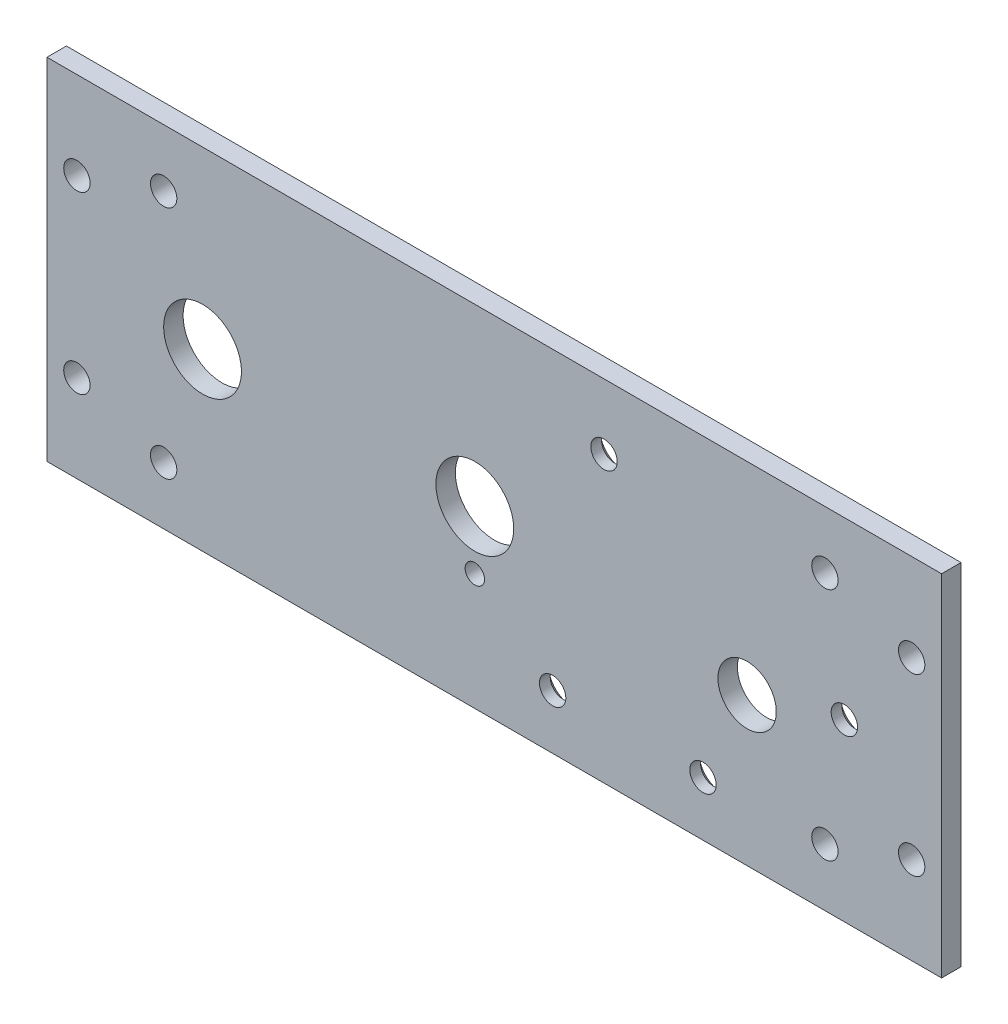
from build123d import *

# Parameters (mm, degrees)
SKETCH1_W                                 = 146.05
SKETCH1_H                                 = 57.15
BOSS_EXTRUDE1_DEPTH                       = 3.175
F_6_CLEARANCE_HOLE1_D                     = 4.3053
F_1_2_0_5_DIAMETER_HOLE1_D                = 12.7
F_3_8_0_375_DIAMETER_HOLE1_D              = 9.525
F_1_8_0_125_DIAMETER_HOLE1_D              = 3.175
CSK_FOR_6_FLAT_HEAD_MACHINE_SCREW_2_COUNT = 2
CSK_FOR_6_FLAT_HEAD_MACHINE_SCREW_2_PITCH = 38.528341037
CSK_FOR_6_FLAT_HEAD_MACHINE_SCREW_3_COUNT = 2
CSK_FOR_6_FLAT_HEAD_MACHINE_SCREW_3_PITCH = 51.534810808
CSK_FOR_6_FLAT_HEAD_MACHINE_SCREW_4_COUNT = 2
CSK_FOR_6_FLAT_HEAD_MACHINE_SCREW_4_PITCH = 24.55


with BuildPart() as part:
    # Sketch1 → Boss-Extrude1 (new body)
    with BuildSketch(Plane.XY):
        with Locations((-73.025, 28.575)):
            Rectangle(SKETCH1_W, SKETCH1_H)
    extrude(amount=-BOSS_EXTRUDE1_DEPTH)

    # #6 Clearance Hole1 (through all)
    with Locations(Plane(origin=(0, 0, -3.175), x_dir=(-1, 0, 0), z_dir=(0, 0, -1))):
        with Locations((4.8895, 42.8625), (141.1605, 42.8625), (141.1605, 14.2875), (4.8895, 14.2875), (19.05, 47.752), (19.05, 9.398), (127, 9.398), (127, 47.752)):
            Hole(F_6_CLEARANCE_HOLE1_D / 2)

    # 1/2 (0.5) Diameter Hole1 (through all)
    with Locations(Plane(origin=(0, 0, -3.175), x_dir=(-1, 0, 0), z_dir=(0, 0, -1))):
        with Locations((76.2, 28.575), (120.65, 28.575)):
            Hole(F_1_2_0_5_DIAMETER_HOLE1_D / 2)

    # 3/8 (0.375) Diameter Hole1 (through all)
    with Locations(Plane(origin=(0, 0, -3.175), x_dir=(-1, 0, 0), z_dir=(0, 0, -1))):
        with Locations((31.75, 24.13)):
            Hole(F_3_8_0_375_DIAMETER_HOLE1_D / 2)

    # 1/8 (0.125) Diameter Hole1 (through all)
    with Locations(Plane(origin=(0, 0, -3.175), x_dir=(-1, 0, 0), z_dir=(0, 0, -1))):
        with Locations((76.2, 19.05)):
            Hole(F_1_8_0_125_DIAMETER_HOLE1_D / 2)

    # Sketch14 → CSK for #6 Flat Head Machine Screw (100)2 (revolve, cut)
    with BuildSketch(Plane(origin=(-63.5, 8.89, -3.175), x_dir=(0, 1, 0), z_dir=(1, 0, 0))):
        Polygon((0, 0), (0, 3.175), (2.15265, 3.175), (2.15265, 1.420893136), (3.8460045, 0), align=None)
    csk_for_6_flat_head_machine_screw_100 = revolve(axis=Axis((-63.5, 8.89, -9.525), (0, 0, 1)), mode=Mode.SUBTRACT)

    # CSK for _6 Flat Head Machine Screw _ 2: CSK for #6 Flat Head Machine Screw (100)2 ×2
    with Locations(*[Vector(0.217814006, 0.975990296, 0) * (i * CSK_FOR_6_FLAT_HEAD_MACHINE_SCREW_2_PITCH) for i in range(1, CSK_FOR_6_FLAT_HEAD_MACHINE_SCREW_2_COUNT)]):
        add(csk_for_6_flat_head_machine_screw_100, mode=Mode.SUBTRACT)

    # CSK for _6 Flat Head Machine Screw _ 3: CSK for #6 Flat Head Machine Screw (100)2 ×2
    with Locations(*[Vector(0.924132625, 0.38207184, 0) * (i * CSK_FOR_6_FLAT_HEAD_MACHINE_SCREW_3_PITCH) for i in range(1, CSK_FOR_6_FLAT_HEAD_MACHINE_SCREW_3_COUNT)]):
        add(csk_for_6_flat_head_machine_screw_100, mode=Mode.SUBTRACT)

    # CSK for _6 Flat Head Machine Screw _ 4: CSK for #6 Flat Head Machine Screw (100)2 ×2
    with Locations(*[(i * CSK_FOR_6_FLAT_HEAD_MACHINE_SCREW_4_PITCH, 0, 0) for i in range(1, CSK_FOR_6_FLAT_HEAD_MACHINE_SCREW_4_COUNT)]):
        add(csk_for_6_flat_head_machine_screw_100, mode=Mode.SUBTRACT)


solid = part.part
